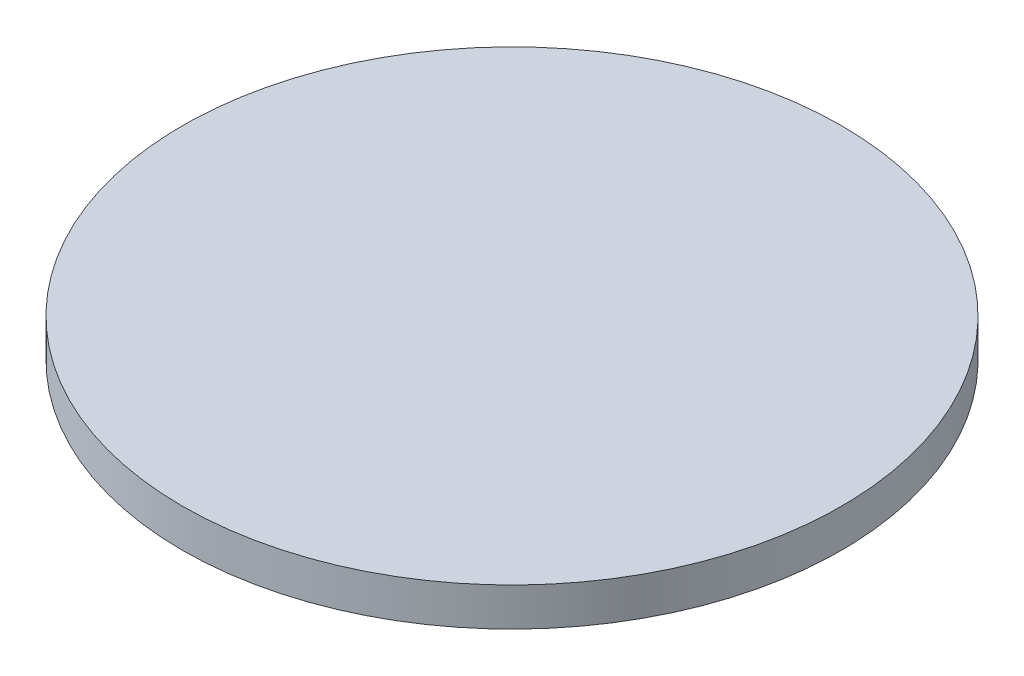
from build123d import *

# Parameters (mm, degrees)
SKETCH1_R      = 109.5375
EXTRUDE1_DEPTH = 12.7


with BuildPart() as part:
    # Sketch1 → Extrude1 (new body)
    with BuildSketch(Plane(origin=(0, 0, 0), x_dir=(1, 0, 0), z_dir=(0, 1, 0))):
        Circle(SKETCH1_R)
    extrude(amount=EXTRUDE1_DEPTH)


solid = part.part
